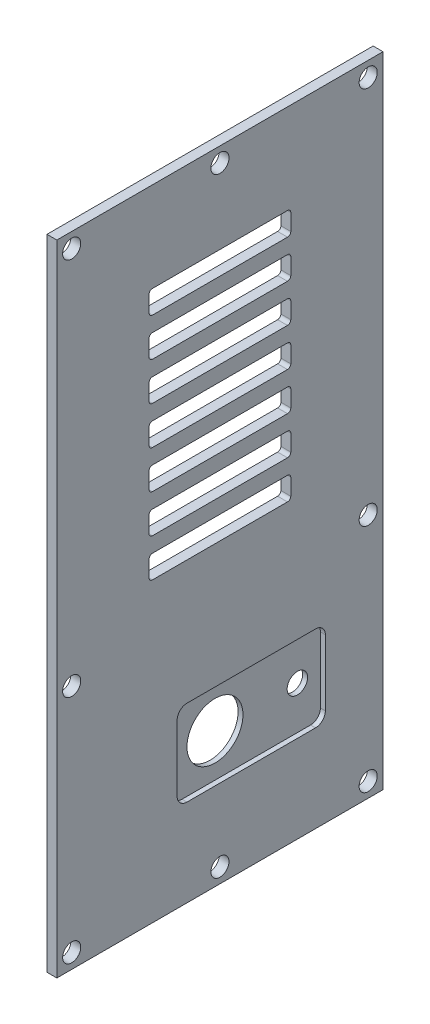
from build123d import *

# Parameters (mm, degrees)
SKETCH1_W           = 99
SKETCH1_H           = 194
BOSS_EXTRUDE1_DEPTH = 3
SKETCH2_W           = 43
SKETCH2_H           = 7
CUT_EXTRUDE1_DEPTH  = 4
FILLET1_R           = 1
SKETCH3_R           = 8.5
SKETCH3_R_2         = 3.1
CUT_EXTRUDE2_DEPTH  = 4
SKETCH4_W           = 45
SKETCH4_H           = 26
CUT_EXTRUDE3_DEPTH  = 1.5
FILLET2_R           = 3
SKETCH5_R           = 2.75
CUT_EXTRUDE4_DEPTH  = 4


with BuildPart() as part:
    # Sketch1 → Boss-Extrude1 (new body)
    with BuildSketch(Plane.ZY.offset(74.98828393)):
        with Locations((-16.230657269, 7.5)):
            Rectangle(SKETCH1_W, SKETCH1_H)
    extrude(amount=BOSS_EXTRUDE1_DEPTH)

    # Sketch2 → Cut-Extrude1 (cut, through all)
    with BuildSketch(Plane.ZY.offset(77.98828393)):
        with Locations((-16.230657269, 73.75)):
            Rectangle(SKETCH2_W, SKETCH2_H)
        with Locations((-16.230657269, 62.15)):
            Rectangle(SKETCH2_W, SKETCH2_H)
        with Locations((-16.230657269, 50.55)):
            Rectangle(SKETCH2_W, SKETCH2_H)
        with Locations((-16.230657269, 38.95)):
            Rectangle(SKETCH2_W, SKETCH2_H)
        with Locations((-16.230657269, 27.35)):
            Rectangle(SKETCH2_W, SKETCH2_H)
        with Locations((-16.230657269, 15.75)):
            Rectangle(SKETCH2_W, SKETCH2_H)
        with Locations((-16.230657269, 4.15)):
            Rectangle(SKETCH2_W, SKETCH2_H)
    extrude(amount=-CUT_EXTRUDE1_DEPTH, mode=Mode.SUBTRACT)

    # Fillet1
    fillet1_edges = [part.edges().sort_by_distance(p)[0] for p in [
        (-76.48828393, 77.25, 5.269342731),
        (-76.48828393, 70.25, 5.269342731),
        (-76.48828393, 70.25, -37.730657269),
        (-76.48828393, 77.25, -37.730657269),
        (-76.48828393, 65.65, 5.269342731),
        (-76.48828393, 58.65, 5.269342731),
        (-76.48828393, 58.65, -37.730657269),
        (-76.48828393, 65.65, -37.730657269),
        (-76.48828393, 54.05, 5.269342731),
        (-76.48828393, 47.05, 5.269342731),
        (-76.48828393, 47.05, -37.730657269),
        (-76.48828393, 54.05, -37.730657269),
        (-76.48828393, 42.45, 5.269342731),
        (-76.48828393, 35.45, 5.269342731),
        (-76.48828393, 35.45, -37.730657269),
        (-76.48828393, 42.45, -37.730657269),
        (-76.48828393, 30.85, 5.269342731),
        (-76.48828393, 23.85, 5.269342731),
        (-76.48828393, 23.85, -37.730657269),
        (-76.48828393, 30.85, -37.730657269),
        (-76.48828393, 19.25, 5.269342731),
        (-76.48828393, 12.25, 5.269342731),
        (-76.48828393, 12.25, -37.730657269),
        (-76.48828393, 19.25, -37.730657269),
        (-76.48828393, 7.65, 5.269342731),
        (-76.48828393, 0.65, 5.269342731),
        (-76.48828393, 0.65, -37.730657269),
        (-76.48828393, 7.65, -37.730657269),
    ]]
    fillet(fillet1_edges, radius=FILLET1_R)

    # Sketch3 → Cut-Extrude2 (cut, through all)
    with BuildSketch(Plane.ZY.offset(77.98828393)):
        with Locations((-16.230657269, -50)):
            Circle(SKETCH3_R)
        with Locations((-41.230657269, -50)):
            Circle(SKETCH3_R_2)
    extrude(amount=-CUT_EXTRUDE2_DEPTH, mode=Mode.SUBTRACT)

    # Sketch4 → Cut-Extrude3 (cut)
    with BuildSketch(Plane(origin=(-74.98828393, 0, 0), x_dir=(0, 0, -1), z_dir=(1, 0, 0))):
        with Locations((25.730657269, -50)):
            Rectangle(SKETCH4_W, SKETCH4_H)
    extrude(amount=-CUT_EXTRUDE3_DEPTH, mode=Mode.SUBTRACT)

    # Fillet2
    fillet2_edges = [part.edges().sort_by_distance(p)[0] for p in [
        (-75.73828393, -37, -48.230657269),
        (-75.73828393, -63, -48.230657269),
        (-75.73828393, -63, -3.230657269),
        (-75.73828393, -37, -3.230657269),
    ]]
    fillet(fillet2_edges, radius=FILLET2_R)

    # Sketch5 → Cut-Extrude4 (cut, through all)
    with BuildSketch(Plane.ZY.offset(77.98828393)):
        with Locations((-61.230657269, 100)):
            Circle(SKETCH5_R)
        with Locations((28.769342731, 100)):
            Circle(SKETCH5_R)
        with Locations((-61.230657269, -15)):
            Circle(SKETCH5_R)
        with Locations((-61.230657269, -85)):
            Circle(SKETCH5_R)
        with Locations((28.769342731, -85)):
            Circle(SKETCH5_R)
        with Locations((28.769342731, -15)):
            Circle(SKETCH5_R)
        with Locations((-16.230657269, 100)):
            Circle(SKETCH5_R)
        with Locations((-16.230657269, -85)):
            Circle(SKETCH5_R)
    extrude(amount=-CUT_EXTRUDE4_DEPTH, mode=Mode.SUBTRACT)


solid = part.part
